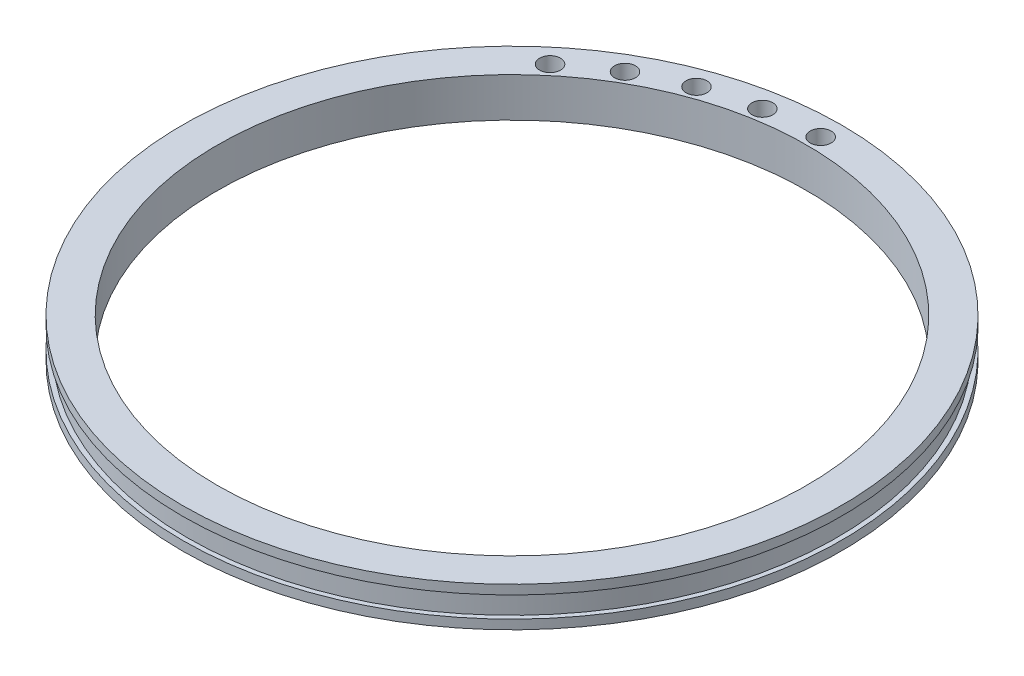
from build123d import *

# Parameters (mm, degrees)
SKETCH1_R               = 70
BOSS_EXTRUDE1_DEPTH     = 2.25
SKETCH2_R               = 71
BOSS_EXTRUDE2_DEPTH     = 2
SKETCH3_R               = 63.5
CUT_EXTRUDE1_DEPTH      = 1
CUT_EXTRUDE1_DEPTH_BACK = 9.5
SKETCH5_R               = 2.25
CUT_EXTRUDE3_DEPTH      = 5.25
CIRPATTERN1_COUNT       = 5
CIRPATTERN1_ANGLE       = 40


with BuildPart() as part:
    # Sketch1 → Boss-Extrude1 (new body, symmetric)
    with BuildSketch(Plane(origin=(0, 0, 0), x_dir=(1, 0, 0), z_dir=(0, 1, 0))):
        Circle(SKETCH1_R)
    extrude(amount=BOSS_EXTRUDE1_DEPTH, both=True)

    # Sketch2 → Boss-Extrude2 (add)
    with BuildSketch(Plane(origin=(0, 2.25, 0), x_dir=(1, 0, 0), z_dir=(0, 1, 0))):
        Circle(SKETCH2_R)
    boss_extrude2 = extrude(amount=BOSS_EXTRUDE2_DEPTH)

    # Mirror1: Boss-Extrude2 across plane
    add(boss_extrude2.mirror(Plane.ZX))

    # Sketch3 → Cut-Extrude1 (cut, two sides)
    with BuildSketch(Plane(origin=(0, 4.25, 0), x_dir=(1, 0, 0), z_dir=(0, 1, 0))) as cut_extrude1_sk:
        Circle(SKETCH3_R)
    extrude(amount=CUT_EXTRUDE1_DEPTH, mode=Mode.SUBTRACT)
    extrude(cut_extrude1_sk.sketch, amount=-CUT_EXTRUDE1_DEPTH_BACK, mode=Mode.SUBTRACT)

    # Sketch5 → Cut-Extrude3 (cut, symmetric)
    with BuildSketch(Plane(origin=(0, 0, 0), x_dir=(1, 0, 0), z_dir=(0, 1, 0))):
        with Locations((0, 66.5)):
            Circle(SKETCH5_R)
    cut_extrude3 = extrude(amount=CUT_EXTRUDE3_DEPTH, both=True, mode=Mode.SUBTRACT)

    # CirPattern1: Cut-Extrude3 ×5 about axis
    cirpattern1_axis = Axis((0, 0, 0), (0, 1, 0))
    for i in range(1, CIRPATTERN1_COUNT):
        add(cut_extrude3.rotate(cirpattern1_axis, i * CIRPATTERN1_ANGLE / (CIRPATTERN1_COUNT - 1)), mode=Mode.SUBTRACT)


solid = part.part
